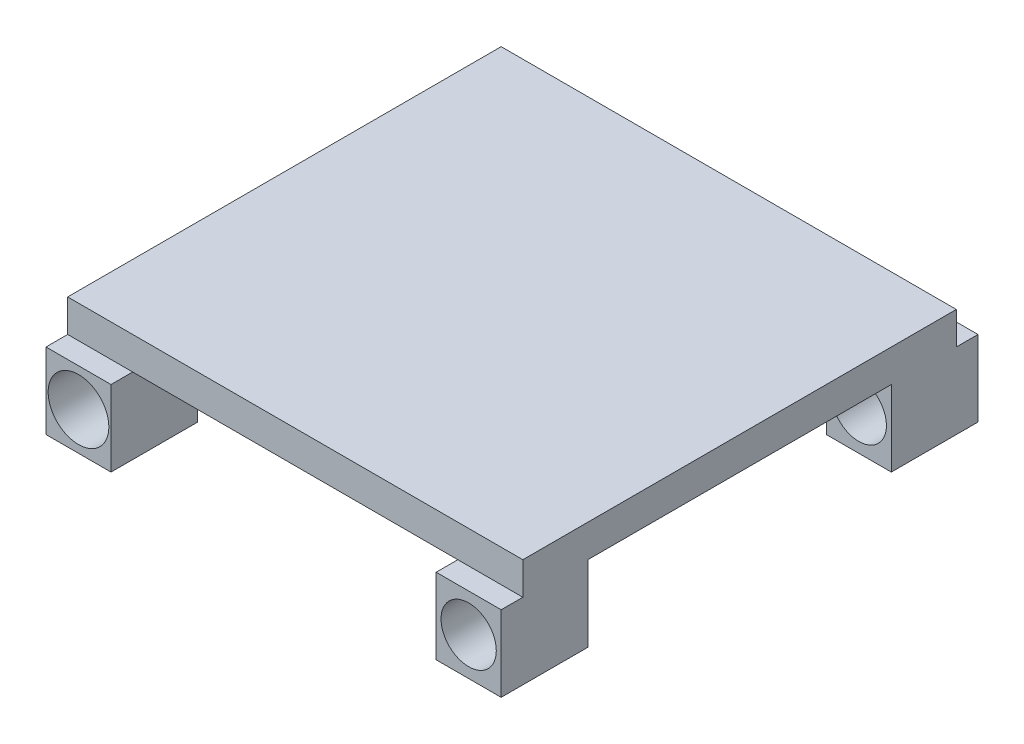
from build123d import *

# Parameters (mm, degrees)
IZIM1_W                     = 210
IZIM1_H                     = 200
Y_KSEKLIK_EKSTR_ZYON1_DEPTH = 15
IZIM2_W                     = 40
IZIM2_H                     = 35
Y_KSEKLIK_EKSTR_ZYON2_DEPTH = 30
IZIM7_R                     = 12.75
IZIM7_R_2                   = 14
KES_EKSTR_ZYON2_DEPTH       = 504


with BuildPart() as part:
    # Çizim1 → Yükseklik-Ekstrüzyon1 (new body)
    with BuildSketch(Plane(origin=(0, 0, 0), x_dir=(1, 0, 0), z_dir=(0, 1, 0))):
        with Locations((-22.864290172, -25)):
            Rectangle(IZIM1_W, IZIM1_H)
    extrude(amount=Y_KSEKLIK_EKSTR_ZYON1_DEPTH)

    # Çizim2 → Yükseklik-Ekstrüzyon2 (add)
    with BuildSketch(Plane(origin=(82.135709828, 0, 0), x_dir=(0, 0, -1), z_dir=(1, 0, 0))):
        with Locations((-115, -17.5)):
            Rectangle(IZIM2_W, IZIM2_H)
        with Locations((65, -17.5)):
            Rectangle(IZIM2_W, IZIM2_H)
    y_kseklik_ekstr_zyon2 = extrude(amount=-Y_KSEKLIK_EKSTR_ZYON2_DEPTH)

    # Aynalama1: Yükseklik-Ekstrüzyon2 across plane
    add(y_kseklik_ekstr_zyon2.mirror(Plane(origin=(-22.864290172, 0, 0), x_dir=(0, 0, 1), z_dir=(1, 0, 0))))

    # Çizim7 → Kes-Ekstrüzyon2 (cut)
    with BuildSketch(Plane.XY.offset(135)):
        with Locations((67.135709828, -17.5)):
            Circle(IZIM7_R)
        with Locations((-112.864290172, -17.5)):
            Circle(IZIM7_R_2)
    extrude(amount=-KES_EKSTR_ZYON2_DEPTH, mode=Mode.SUBTRACT)


solid = part.part
